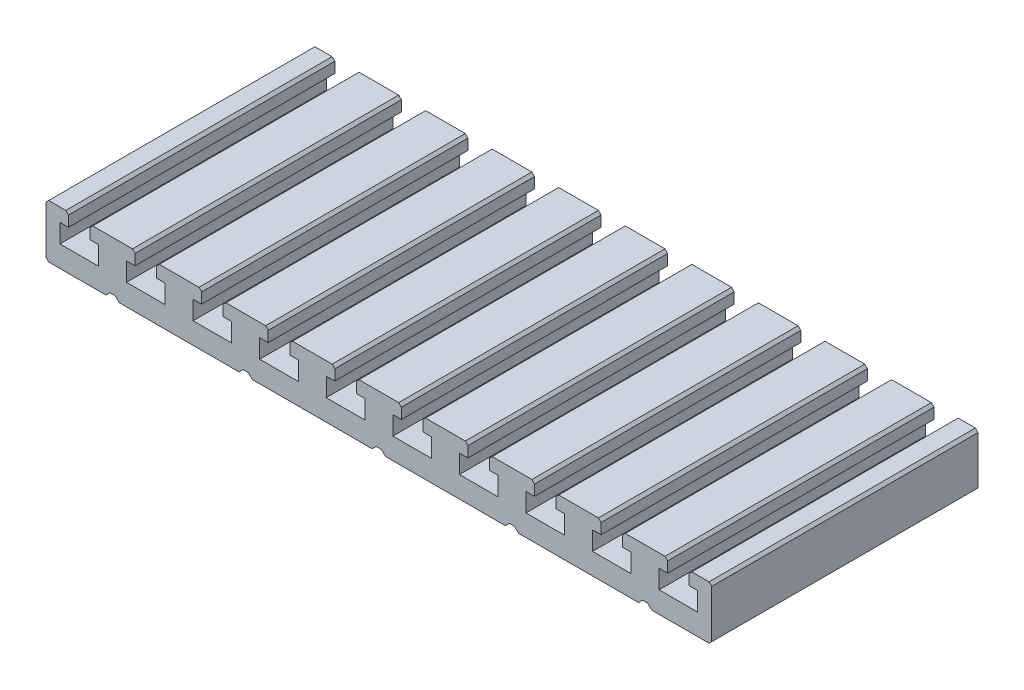
from build123d import *

# Parameters (mm, degrees)
EXTRUDE_1_DEPTH = 100


with BuildPart() as part:
    # Эскиз1 → Бобышка-Вытянуть1 (new body)
    with BuildSketch(Plane.XY):
        Polygon((-52.5, 0), (-51, 1.5), (-49, 1.5), (-47.5, 0), (-2.5, 0), (-1, 1.5), (1, 1.5), (2.5, 0), (47.5, 0), (49, 1.5), (51, 1.5), (52.5, 0), (97.5, 0), (99, 1.5), (101, 1.5), (102.5, 0), (124, 0), (125, 1), (125, 19), (124, 20), (117.55, 20), (116.55, 19), (116.55, 15), (119.75, 15), (119.75, 8), (105.25, 8), (105.25, 15), (108.45, 15), (108.45, 19), (107.45, 20), (92.55, 20), (91.55, 19), (91.55, 15), (94.75, 15), (94.75, 8), (80.25, 8), (80.25, 15), (83.45, 15), (83.45, 19), (82.45, 20), (67.55, 20), (66.55, 19), (66.55, 15), (69.75, 15), (69.75, 8), (55.25, 8), (55.25, 15), (58.45, 15), (58.45, 19), (57.45, 20), (42.55, 20), (41.55, 19), (41.55, 15), (44.75, 15), (44.75, 8), (30.25, 8), (30.25, 15), (33.45, 15), (33.45, 19), (32.45, 20), (17.55, 20), (16.55, 19), (16.55, 15), (19.75, 15), (19.75, 8), (5.25, 8), (5.25, 15), (8.45, 15), (8.45, 19), (7.45, 20), (-7.45, 20), (-8.45, 19), (-8.45, 15), (-5.25, 15), (-5.25, 8), (-19.75, 8), (-19.75, 15), (-16.55, 15), (-16.55, 19), (-17.55, 20), (-32.45, 20), (-33.45, 19), (-33.45, 15), (-30.25, 15), (-30.25, 8), (-44.75, 8), (-44.75, 15), (-41.55, 15), (-41.55, 19), (-42.55, 20), (-57.45, 20), (-58.45, 19), (-58.45, 15), (-55.25, 15), (-55.25, 8), (-69.75, 8), (-69.75, 15), (-66.55, 15), (-66.55, 19), (-67.55, 20), (-82.45, 20), (-83.45, 19), (-83.45, 15), (-80.25, 15), (-80.25, 8), (-94.75, 8), (-94.75, 15), (-91.55, 15), (-91.55, 19), (-92.55, 20), (-107.45, 20), (-108.45, 19), (-108.45, 15), (-105.25, 15), (-105.25, 8), (-119.75, 8), (-119.75, 15), (-116.55, 15), (-116.55, 19), (-117.55, 20), (-124, 20), (-125, 19), (-125, 1), (-124, 0), (-102.5, 0), (-101, 1.5), (-99, 1.5), (-97.5, 0), align=None)
    extrude(amount=-EXTRUDE_1_DEPTH)


solid = part.part
